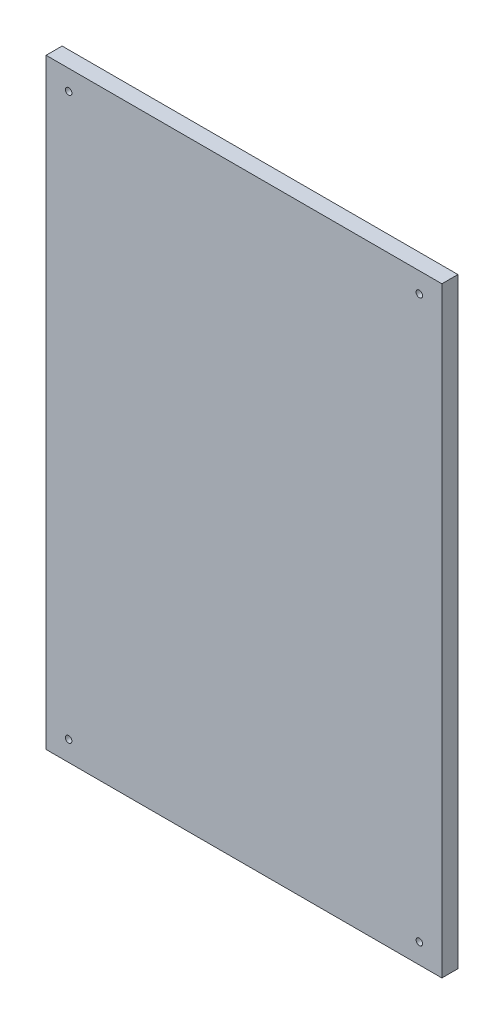
from build123d import *

# Parameters (mm, degrees)
SKETCH1_W           = 395
SKETCH1_H           = 600
BOSS_EXTRUDE1_DEPTH = 16
SKETCH2_R           = 3.25
CUT_EXTRUDE1_DEPTH  = 17


with BuildPart() as part:
    # Sketch1 → Boss-Extrude1 (new body)
    with BuildSketch(Plane.XY):
        with Locations((197.5, 300)):
            Rectangle(SKETCH1_W, SKETCH1_H)
    extrude(amount=BOSS_EXTRUDE1_DEPTH)

    # Sketch2 → Cut-Extrude1 (cut, through all)
    with BuildSketch(Plane.XY.offset(16)):
        with Locations((22.5, 580)):
            Circle(SKETCH2_R)
        with Locations((372.5, 580)):
            Circle(SKETCH2_R)
        with Locations((22.5, 20)):
            Circle(SKETCH2_R)
        with Locations((372.5, 20)):
            Circle(SKETCH2_R)
    extrude(amount=-CUT_EXTRUDE1_DEPTH, mode=Mode.SUBTRACT)


solid = part.part
